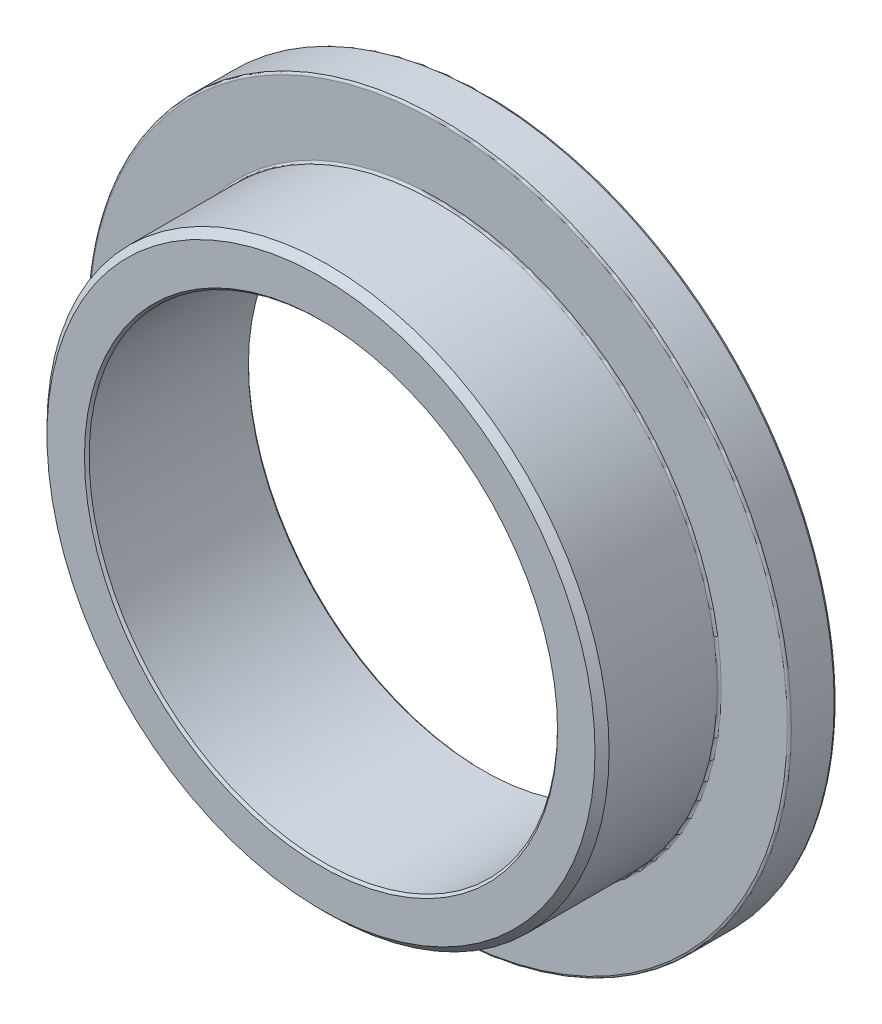
from build123d import *

# Parameters (mm, degrees)
CHAMFER1_SIZE = 0.15
CHAMFER2_SIZE = 0.05
FILLET1_R     = 0.045


with BuildPart() as part:
    # Sketch3 → Revolve1 (revolve)
    with BuildSketch(Plane(origin=(0, 0, 0), x_dir=(0, 0, -1), z_dir=(1, 0, 0))):
        Polygon((1.75, -7.5), (0.75, -7.5), (0.75, -6), (-1.75, -6), (-1.75, -5), (1.75, -5), align=None)
    revolve(axis=Axis((0, 0, 1.75), (0, 0, -1)))

    # Chamfer1
    chamfer1_edges = [part.edges().sort_by_distance(p)[0] for p in [
        (0, 6, 1.75),
    ]]
    chamfer(chamfer1_edges, length=CHAMFER1_SIZE)

    # Chamfer2
    chamfer2_edges = [part.edges().sort_by_distance(p)[0] for p in [
        (0, 5, -1.75),
        (0, 5, 1.75),
    ]]
    chamfer(chamfer2_edges, length=CHAMFER2_SIZE)

    # Fillet1
    fillet1_edges = [part.edges().sort_by_distance(p)[0] for p in [
        (0, 6, -0.75),
        (0, 7.5, -0.75),
        (0, 7.5, -1.75),
    ]]
    fillet(fillet1_edges, radius=FILLET1_R)


solid = part.part
